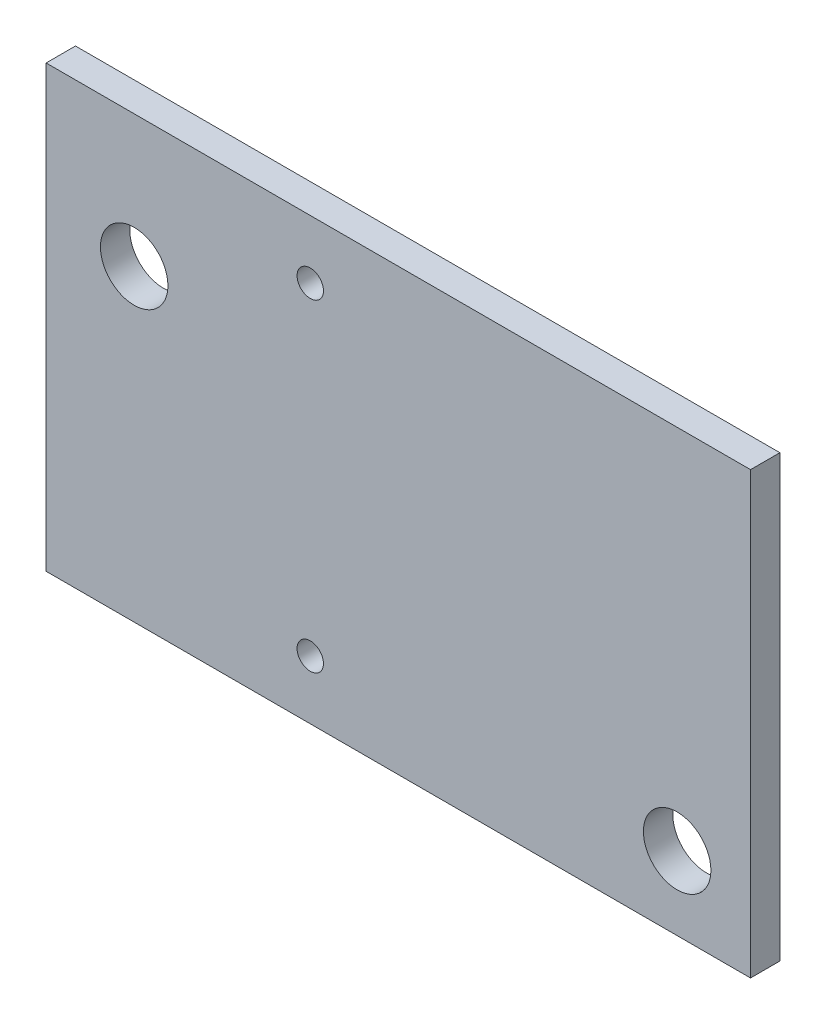
from build123d import *

# Parameters (mm, degrees)
SKETCH_1_W      = 24
SKETCH_1_H      = 15
SKETCH_1_R      = 1.15
SKETCH_1_R_2    = 0.45
EXTRUDE_1_DEPTH = 1


with BuildPart() as part:
    # Эскиз1 → Бобышка-Вытянуть1 (new body)
    with BuildSketch(Plane.XY):
        with Locations((12, 7.5)):
            Rectangle(SKETCH_1_W, SKETCH_1_H)
        with Locations((3, 10.5)):
            Circle(SKETCH_1_R, mode=Mode.SUBTRACT)
        with Locations((21.5, 2.5)):
            Circle(SKETCH_1_R, mode=Mode.SUBTRACT)
        with Locations((9, 13)):
            Circle(SKETCH_1_R_2, mode=Mode.SUBTRACT)
        with Locations((9, 2)):
            Circle(SKETCH_1_R_2, mode=Mode.SUBTRACT)
    extrude(amount=EXTRUDE_1_DEPTH)


solid = part.part
